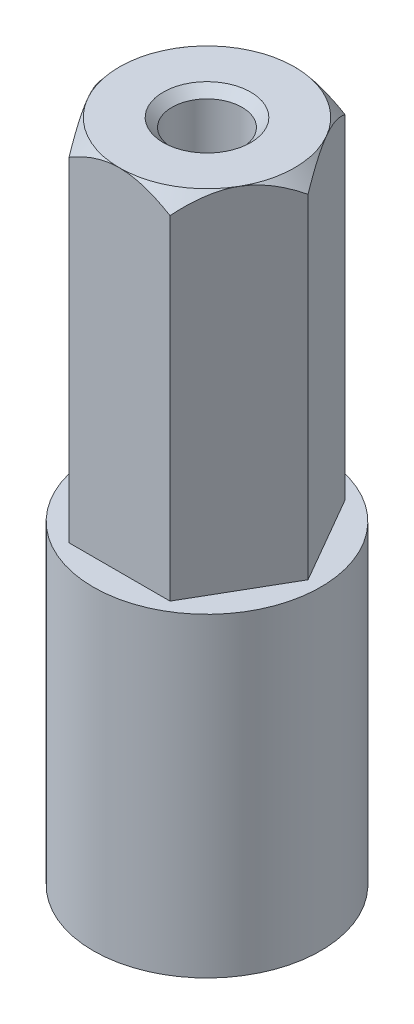
from build123d import *

# Parameters (mm, degrees)
SKETCH1_R                                         = 3.25
SKETCH1_R_2                                       = 1.5
BOSS_EXTRUDE1_DEPTH                               = 6
SKETCH2_R                                         = 3.25
BOSS_EXTRUDE2_DEPTH                               = 3
BOSS_EXTRUDE3_DEPTH                               = 10
SKETCH4_OUTSIDE_W                                 = 29.504
SKETCH4_OUTSIDE_H                                 = 29.504
SKETCH4_OUTSIDE_R                                 = 2.5
CUT_EXTRUDE1_DEPTH                                = 10
CUT_EXTRUDE1_TAPER                                = 40
CSK_FOR_M2_5_FLAT_HEAD_MACHINE_SCREW1_D           = 2
CSK_FOR_M2_5_FLAT_HEAD_MACHINE_SCREW1_DEPTH       = 6
CSK_FOR_M2_5_FLAT_HEAD_MACHINE_SCREW1_CSINK_D     = 2.5
CSK_FOR_M2_5_FLAT_HEAD_MACHINE_SCREW1_CSINK_ANGLE = 90
CSK_FOR_M2_5_FLAT_HEAD_MACHINE_SCREW1_TIP         = 0.600860619
SKETCH8_R                                         = 1.5
CUT_EXTRUDE2_DEPTH                                = 4.25


with BuildPart() as part:
    # Sketch1 → Boss-Extrude1 (new body)
    with BuildSketch(Plane(origin=(0, 0, 0), x_dir=(1, 0, 0), z_dir=(0, 1, 0))):
        Circle(SKETCH1_R)
        Circle(SKETCH1_R_2, mode=Mode.SUBTRACT)
    extrude(amount=BOSS_EXTRUDE1_DEPTH)

    # Sketch2 → Boss-Extrude2 (add)
    with BuildSketch(Plane(origin=(0, 6, 0), x_dir=(1, 0, 0), z_dir=(0, 1, 0))):
        Circle(SKETCH2_R)
    extrude(amount=BOSS_EXTRUDE2_DEPTH)

    # Sketch3 → Boss-Extrude3 (add)
    with BuildSketch(Plane(origin=(0, 9, 0), x_dir=(1, 0, 0), z_dir=(0, 1, 0))):
        Polygon((2.886751346, 0), (1.443375673, 2.5), (-1.443375673, 2.5), (-2.886751346, 0), (-1.443375673, -2.5), (1.443375673, -2.5), align=None)
    extrude(amount=BOSS_EXTRUDE3_DEPTH)

    # Sketch4 outside → Cut-Extrude1 (cut)
    with BuildSketch(Plane(origin=(0, 19, 0), x_dir=(1, 0, 0), z_dir=(0, 1, 0))):
        Rectangle(SKETCH4_OUTSIDE_W, SKETCH4_OUTSIDE_H)
        Circle(SKETCH4_OUTSIDE_R, mode=Mode.SUBTRACT)
    extrude(amount=-CUT_EXTRUDE1_DEPTH, taper=CUT_EXTRUDE1_TAPER, mode=Mode.SUBTRACT)

    # CSK for M2.5 Flat Head Machine Screw1
    with Locations(Plane(origin=(0, 19, 0), x_dir=(1, 0, 0), z_dir=(0, 1, 0))):
        with Locations((0, 0)):
            CounterSinkHole(CSK_FOR_M2_5_FLAT_HEAD_MACHINE_SCREW1_D / 2, CSK_FOR_M2_5_FLAT_HEAD_MACHINE_SCREW1_CSINK_D / 2, depth=CSK_FOR_M2_5_FLAT_HEAD_MACHINE_SCREW1_DEPTH, counter_sink_angle=CSK_FOR_M2_5_FLAT_HEAD_MACHINE_SCREW1_CSINK_ANGLE)
            with Locations((0, 0, -(CSK_FOR_M2_5_FLAT_HEAD_MACHINE_SCREW1_DEPTH + CSK_FOR_M2_5_FLAT_HEAD_MACHINE_SCREW1_TIP / 2))):  # 118° drill point
                Cone(0, CSK_FOR_M2_5_FLAT_HEAD_MACHINE_SCREW1_D / 2, CSK_FOR_M2_5_FLAT_HEAD_MACHINE_SCREW1_TIP, mode=Mode.SUBTRACT)

    # Sketch8 → Cut-Extrude2 (cut, through all)
    with BuildSketch(Plane(origin=(0, 0, 0), x_dir=(0, 0, -1), z_dir=(1, 0, 0))):
        with Locations((0, 4)):
            Circle(SKETCH8_R)
    extrude(amount=-CUT_EXTRUDE2_DEPTH, mode=Mode.SUBTRACT)


solid = part.part
